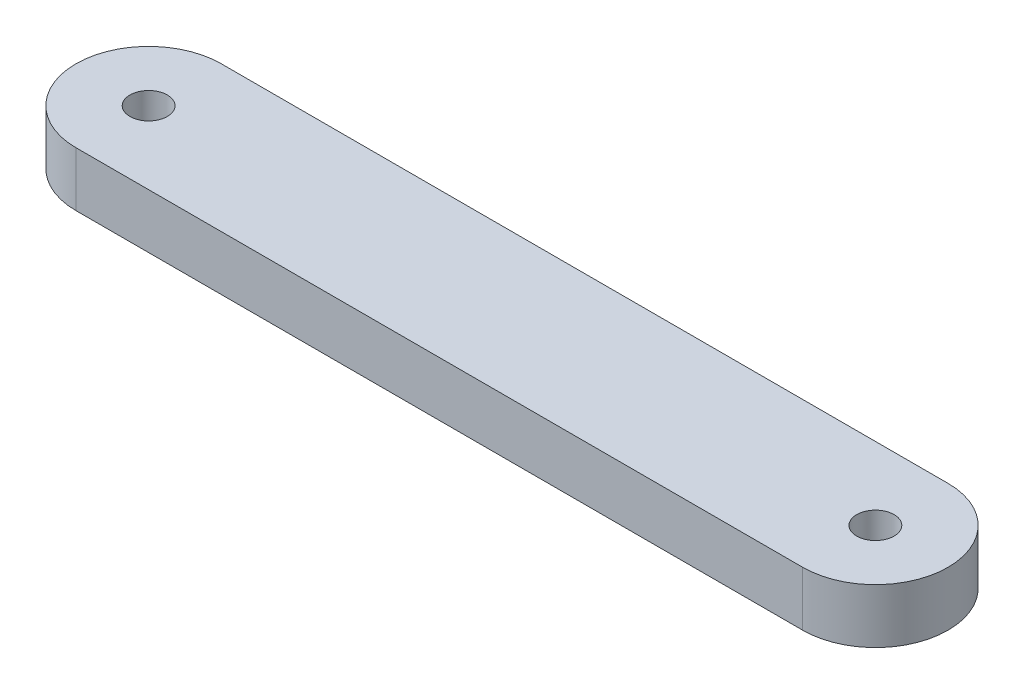
from build123d import *

# Parameters (mm, degrees)
BOSS_EXTRUDE2_DEPTH                               = 4.7625
F_4_CLEARANCE_HOLE1_D                             = 3.2639
CSK_FOR_4_FLAT_HEAD_SOCKET_CAP_SCREW2_D           = 3.2639
CSK_FOR_4_FLAT_HEAD_SOCKET_CAP_SCREW2_CSINK_D     = 6.477
CSK_FOR_4_FLAT_HEAD_SOCKET_CAP_SCREW2_CSINK_ANGLE = 82


with BuildPart() as part:
    # Sketch1 → Boss-Extrude2 (new body)
    with BuildSketch(Plane(origin=(0, 0, 0), x_dir=(1, 0, 0), z_dir=(0, 1, 0))):
        with BuildLine():
            Line((-63.5, 6.35), (0, 6.35))
            ThreePointArc((0, 6.35), (6.35, 0), (0, -6.35))
            Line((0, -6.35), (-63.5, -6.35))
            ThreePointArc((-63.5, -6.35), (-69.85, 0), (-63.5, 6.35))
        make_face()
    extrude(amount=BOSS_EXTRUDE2_DEPTH)

    # #4 Clearance Hole1 (through all)
    with Locations(Plane(origin=(0, 4.7625, 0), x_dir=(1, 0, 0), z_dir=(0, 1, 0))):
        with Locations((-63.5, 0)):
            Hole(F_4_CLEARANCE_HOLE1_D / 2)

    # CSK for #4 Flat Head Socket Cap Screw2 (through all)
    with Locations(Plane(origin=(0, 0, 0), x_dir=(-1, 0, 0), z_dir=(0, -1, 0))):
        with Locations((0, 0)):
            CounterSinkHole(CSK_FOR_4_FLAT_HEAD_SOCKET_CAP_SCREW2_D / 2, CSK_FOR_4_FLAT_HEAD_SOCKET_CAP_SCREW2_CSINK_D / 2, counter_sink_angle=CSK_FOR_4_FLAT_HEAD_SOCKET_CAP_SCREW2_CSINK_ANGLE)


solid = part.part
